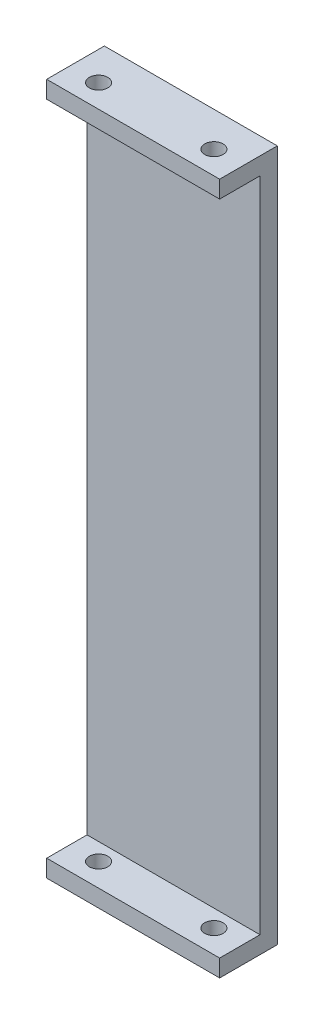
from build123d import *

# Parameters (mm, degrees)
SKETCH_1_W          = 30
SKETCH_1_H          = 120
EXTRUDE_1_DEPTH     = 10
SKETCH_2_W          = 30
SKETCH_2_H          = 114
CUT_EXTRUDE_1_DEPTH = 7
SKETCH_3_R          = 1.6
CUT_EXTRUDE_2_DEPTH = 121


with BuildPart() as part:
    # 草图1 → 凸台-拉伸1 (new body)
    with BuildSketch(Plane.XY):
        with Locations((4.914157805, 54.268009127)):
            Rectangle(SKETCH_1_W, SKETCH_1_H)
    extrude(amount=EXTRUDE_1_DEPTH)

    # 草图2 → 切除-拉伸1 (cut)
    with BuildSketch(Plane.XY.offset(10)):
        with Locations((4.914157805, 54.268009127)):
            Rectangle(SKETCH_2_W, SKETCH_2_H)
    extrude(amount=-CUT_EXTRUDE_1_DEPTH, mode=Mode.SUBTRACT)

    # 草图3 → 切除-拉伸2 (cut, through all)
    with BuildSketch(Plane(origin=(0, 114.268009127, 0), x_dir=(1, 0, 0), z_dir=(0, 1, 0))):
        with Locations((-5.085842195, -6)):
            Circle(SKETCH_3_R)
        with Locations((14.914157805, -6)):
            Circle(SKETCH_3_R)
    extrude(amount=-CUT_EXTRUDE_2_DEPTH, mode=Mode.SUBTRACT)


solid = part.part
